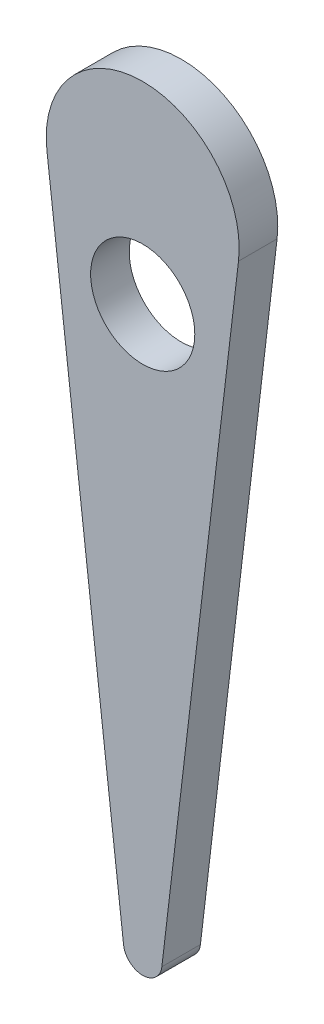
from build123d import *

# Parameters (mm, degrees)
IZIM1_R                     = 13.5
Y_KSEKLIK_EKSTR_ZYON1_DEPTH = 10


with BuildPart() as part:
    # Çizim1 → Yükseklik-Ekstrüzyon1 (new body)
    with BuildSketch(Plane.XY):
        with BuildLine():
            Line((24.827715658, 22.070062253), (4.965543132, -146.238077514))
            ThreePointArc((4.965543132, -146.238077514), (0, -150.652089965), (-4.965543132, -146.238077514))
            Line((-4.965543132, -146.238077514), (-24.827715658, 22.070062253))
            ThreePointArc((-24.827715658, 22.070062253), (0, 50), (24.827715658, 22.070062253))
        make_face()
        Circle(IZIM1_R, mode=Mode.SUBTRACT)
    extrude(amount=Y_KSEKLIK_EKSTR_ZYON1_DEPTH)


solid = part.part
